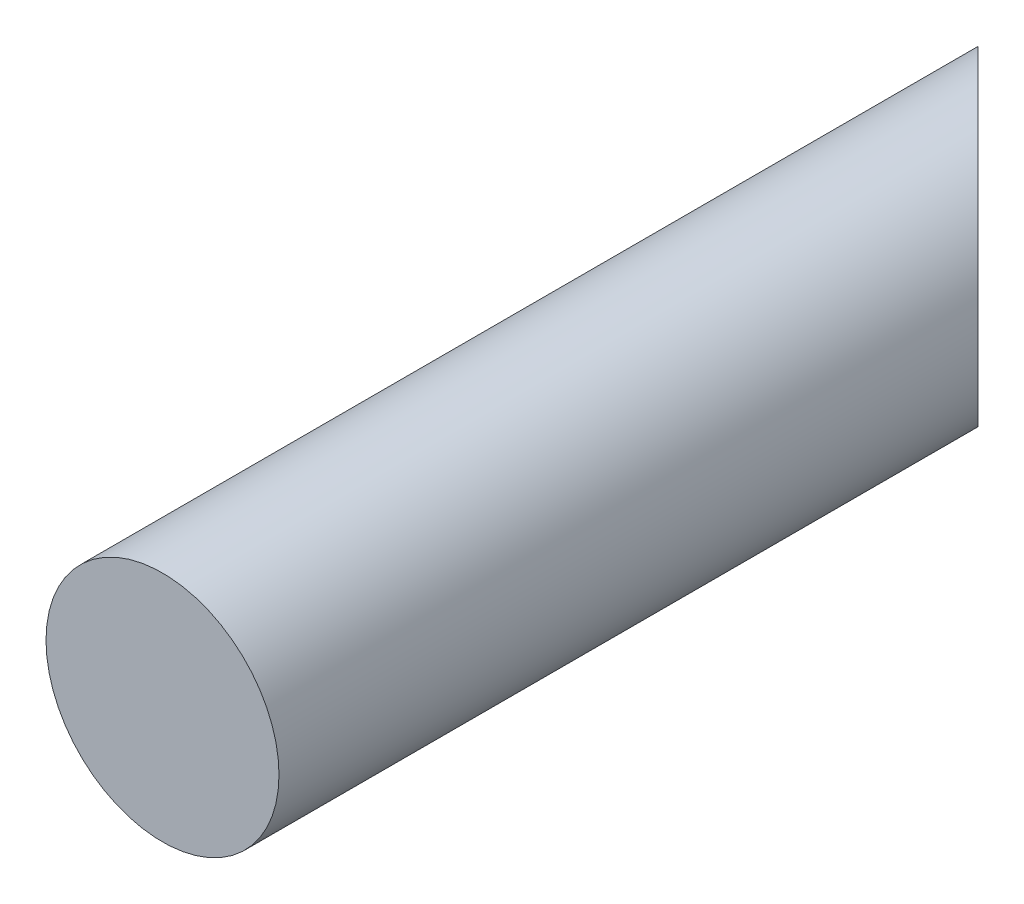
from build123d import *

# Parameters (mm, degrees)
SKETCH1_R           = 30
BOSS_EXTRUDE2_DEPTH = 240
CUT_EXTRUDE1_DEPTH  = 70


with BuildPart() as part:
    # Sketch1 → Boss-Extrude2 (new body)
    with BuildSketch(Plane.XY):
        Circle(SKETCH1_R)
    extrude(amount=BOSS_EXTRUDE2_DEPTH)

    # Sketch3 → Cut-Extrude1 (cut)
    with BuildSketch(Plane(origin=(0, 40, 0), x_dir=(1, 0, 0), z_dir=(0, 1, 0))):
        Polygon((-30, 0), (30, -60), (30, 0), align=None)
    extrude(amount=-CUT_EXTRUDE1_DEPTH, mode=Mode.SUBTRACT)


solid = part.part
